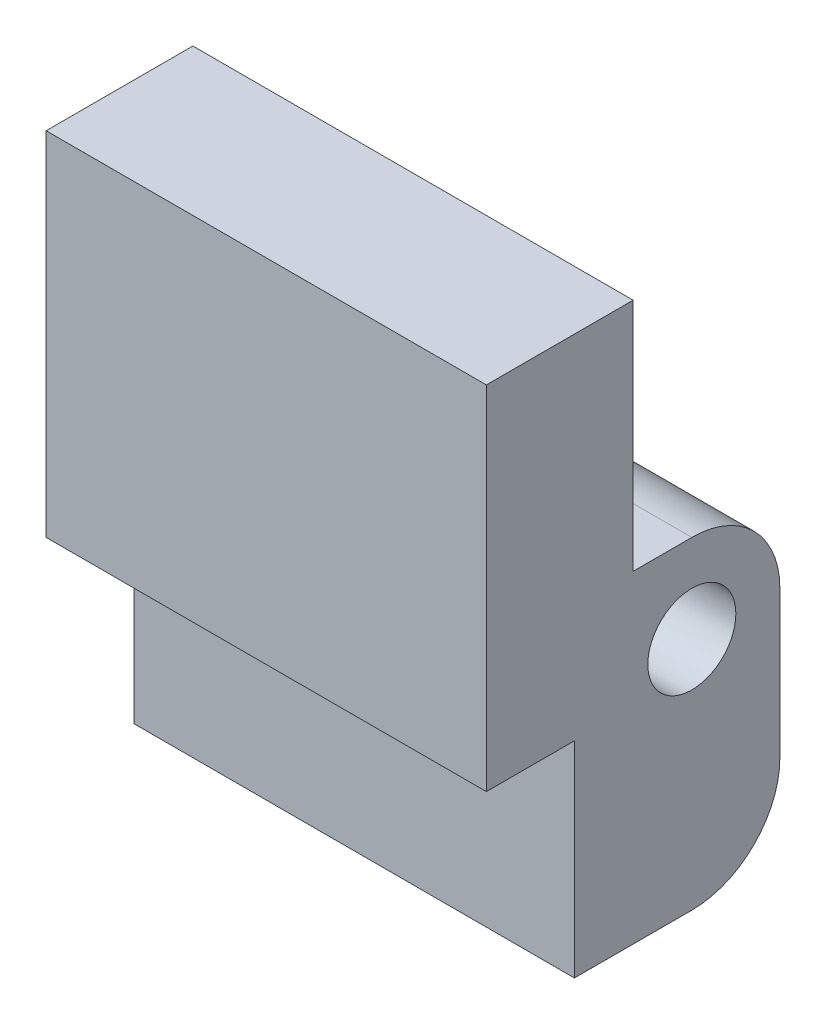
from build123d import *

# Parameters (mm, degrees)
SKETCH1_R           = 1.5
BOSS_EXTRUDE1_DEPTH = 15


with BuildPart() as part:
    # Sketch1 → Boss-Extrude1 (new body)
    with BuildSketch(Plane(origin=(0, 0, 0), x_dir=(0, 0, -1), z_dir=(1, 0, 0))):
        with BuildLine():
            Line((-2.147887324, 5.126760563), (2.852112676, 5.126760563))
            Line((2.852112676, 5.126760563), (2.852112676, -2.873239437))
            Line((2.852112676, -2.873239437), (4.852112676, -2.873239437))
            ThreePointArc((4.852112676, -2.873239437), (6.97343302, -3.751919093), (7.852112676, -5.873239437))
            Line((7.852112676, -5.873239437), (7.852112676, -10.873239437))
            ThreePointArc((7.852112676, -10.873239437), (6.97343302, -12.99455978), (4.852112676, -13.873239437))
            Line((4.852112676, -13.873239437), (0.852112676, -13.873239437))
            Line((0.852112676, -13.873239437), (0.852112676, -6.873239437))
            Line((0.852112676, -6.873239437), (-2.147887324, -6.873239437))
            Line((-2.147887324, -6.873239437), (-2.147887324, 5.126760563))
        make_face()
        with Locations((4.852112676, -5.873239437)):
            Circle(SKETCH1_R, mode=Mode.SUBTRACT)
    extrude(amount=BOSS_EXTRUDE1_DEPTH)


solid = part.part
